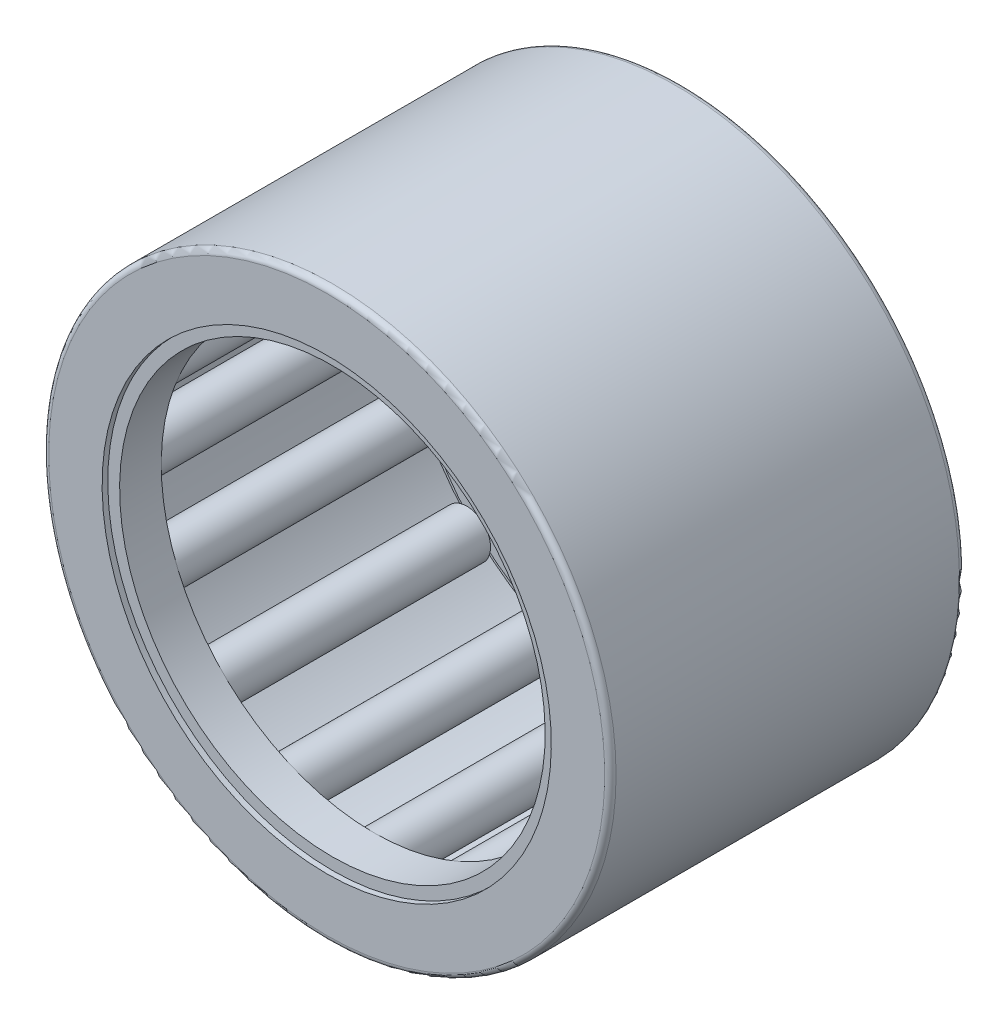
from build123d import *

# Parameters (mm, degrees)
SKETCH2_W         = 11.641666666
SKETCH2_H         = 0.79375
SKETCH3_W         = 13.758333334
SKETCH3_H         = 0.264583334
CIRPATTERN1_COUNT = 16
CIRPATTERN1_ANGLE = 337.5
FILLET1_R         = 0.254
SKETCH4_W         = 1.862666667
SKETCH4_H         = 0.529166667
SKETCH5_W         = 1.862666667
SKETCH5_H         = 0.529166667


with BuildPart() as part:
    # Sketch1 → Revolve1 (revolve)
    with BuildSketch(Plane(origin=(0, 0, 0), x_dir=(0, 0, -1), z_dir=(1, 0, 0))):
        Polygon((-7.9375, 12.7), (7.9375, 12.7), (7.9375, 10.054166667), (6.879166667, 10.054166667), (6.879166667, 11.641666667), (-6.879166667, 11.641666667), (-6.879166667, 10.054166667), (-7.9375, 10.054166667), align=None)
    revolve(axis=Axis((0, 0, 7.9375), (0, 0, -1)))

    # Fillet1
    fillet1_edges = [part.edges().sort_by_distance(p)[0] for p in [
        (0, -12.7, 7.9375),
        (0, -12.7, -7.9375),
    ]]
    fillet(fillet1_edges, radius=FILLET1_R)


with BuildPart() as body_2:
    # Sketch2 → Revolve2 (revolve)
    with BuildSketch(Plane(origin=(0, 0, 0), x_dir=(0, 0, -1), z_dir=(1, 0, 0))):
        with Locations((0, 11.244791667)):
            Rectangle(SKETCH2_W, SKETCH2_H)
    revolve(axis=Axis((0, 10.583333333, 5.820833333), (0, 0, -1)))


with BuildPart() as body_3:
    # Sketch3 → Revolve3 (revolve)
    with BuildSketch(Plane(origin=(0, 0, 0), x_dir=(0, 0, -1), z_dir=(1, 0, 0))):
        with Locations((0, 10.715625)):
            Rectangle(SKETCH3_W, SKETCH3_H)
    revolve(axis=Axis((0, 10.583333333, 6.879166667), (0, 0, -1)))


with BuildPart() as cirpattern1_1:
    # CirPattern1: pattern copy
    add(body_2.part.rotate(Axis((0, 0, -7.9375), (0, 0, 1)), 1 * CIRPATTERN1_ANGLE / (CIRPATTERN1_COUNT - 1)))


with BuildPart() as cirpattern1_2:
    # CirPattern1: pattern copy
    add(body_2.part.rotate(Axis((0, 0, -7.9375), (0, 0, 1)), 2 * CIRPATTERN1_ANGLE / (CIRPATTERN1_COUNT - 1)))


with BuildPart() as cirpattern1_3:
    # CirPattern1: pattern copy
    add(body_2.part.rotate(Axis((0, 0, -7.9375), (0, 0, 1)), 3 * CIRPATTERN1_ANGLE / (CIRPATTERN1_COUNT - 1)))


with BuildPart() as cirpattern1_4:
    # CirPattern1: pattern copy
    add(body_2.part.rotate(Axis((0, 0, -7.9375), (0, 0, 1)), 4 * CIRPATTERN1_ANGLE / (CIRPATTERN1_COUNT - 1)))


with BuildPart() as cirpattern1_5:
    # CirPattern1: pattern copy
    add(body_2.part.rotate(Axis((0, 0, -7.9375), (0, 0, 1)), 5 * CIRPATTERN1_ANGLE / (CIRPATTERN1_COUNT - 1)))


with BuildPart() as cirpattern1_6:
    # CirPattern1: pattern copy
    add(body_2.part.rotate(Axis((0, 0, -7.9375), (0, 0, 1)), 6 * CIRPATTERN1_ANGLE / (CIRPATTERN1_COUNT - 1)))


with BuildPart() as cirpattern1_7:
    # CirPattern1: pattern copy
    add(body_2.part.rotate(Axis((0, 0, -7.9375), (0, 0, 1)), 7 * CIRPATTERN1_ANGLE / (CIRPATTERN1_COUNT - 1)))


with BuildPart() as cirpattern1_8:
    # CirPattern1: pattern copy
    add(body_2.part.rotate(Axis((0, 0, -7.9375), (0, 0, 1)), 8 * CIRPATTERN1_ANGLE / (CIRPATTERN1_COUNT - 1)))


with BuildPart() as cirpattern1_9:
    # CirPattern1: pattern copy
    add(body_2.part.rotate(Axis((0, 0, -7.9375), (0, 0, 1)), 9 * CIRPATTERN1_ANGLE / (CIRPATTERN1_COUNT - 1)))


with BuildPart() as cirpattern1_10:
    # CirPattern1: pattern copy
    add(body_2.part.rotate(Axis((0, 0, -7.9375), (0, 0, 1)), 10 * CIRPATTERN1_ANGLE / (CIRPATTERN1_COUNT - 1)))


with BuildPart() as cirpattern1_11:
    # CirPattern1: pattern copy
    add(body_2.part.rotate(Axis((0, 0, -7.9375), (0, 0, 1)), 11 * CIRPATTERN1_ANGLE / (CIRPATTERN1_COUNT - 1)))


with BuildPart() as cirpattern1_12:
    # CirPattern1: pattern copy
    add(body_2.part.rotate(Axis((0, 0, -7.9375), (0, 0, 1)), 12 * CIRPATTERN1_ANGLE / (CIRPATTERN1_COUNT - 1)))


with BuildPart() as cirpattern1_13:
    # CirPattern1: pattern copy
    add(body_2.part.rotate(Axis((0, 0, -7.9375), (0, 0, 1)), 13 * CIRPATTERN1_ANGLE / (CIRPATTERN1_COUNT - 1)))


with BuildPart() as cirpattern1_14:
    # CirPattern1: pattern copy
    add(body_2.part.rotate(Axis((0, 0, -7.9375), (0, 0, 1)), 14 * CIRPATTERN1_ANGLE / (CIRPATTERN1_COUNT - 1)))


with BuildPart() as cirpattern1_15:
    # CirPattern1: pattern copy
    add(body_2.part.rotate(Axis((0, 0, -7.9375), (0, 0, 1)), 15 * CIRPATTERN1_ANGLE / (CIRPATTERN1_COUNT - 1)))


with BuildPart() as cirpattern1_16:
    # CirPattern1: pattern copy
    add(body_3.part.rotate(Axis((0, 0, -7.9375), (0, 0, 1)), 1 * CIRPATTERN1_ANGLE / (CIRPATTERN1_COUNT - 1)))


with BuildPart() as cirpattern1_17:
    # CirPattern1: pattern copy
    add(body_3.part.rotate(Axis((0, 0, -7.9375), (0, 0, 1)), 2 * CIRPATTERN1_ANGLE / (CIRPATTERN1_COUNT - 1)))


with BuildPart() as cirpattern1_18:
    # CirPattern1: pattern copy
    add(body_3.part.rotate(Axis((0, 0, -7.9375), (0, 0, 1)), 3 * CIRPATTERN1_ANGLE / (CIRPATTERN1_COUNT - 1)))


with BuildPart() as cirpattern1_19:
    # CirPattern1: pattern copy
    add(body_3.part.rotate(Axis((0, 0, -7.9375), (0, 0, 1)), 4 * CIRPATTERN1_ANGLE / (CIRPATTERN1_COUNT - 1)))


with BuildPart() as cirpattern1_20:
    # CirPattern1: pattern copy
    add(body_3.part.rotate(Axis((0, 0, -7.9375), (0, 0, 1)), 5 * CIRPATTERN1_ANGLE / (CIRPATTERN1_COUNT - 1)))


with BuildPart() as cirpattern1_21:
    # CirPattern1: pattern copy
    add(body_3.part.rotate(Axis((0, 0, -7.9375), (0, 0, 1)), 6 * CIRPATTERN1_ANGLE / (CIRPATTERN1_COUNT - 1)))


with BuildPart() as cirpattern1_22:
    # CirPattern1: pattern copy
    add(body_3.part.rotate(Axis((0, 0, -7.9375), (0, 0, 1)), 7 * CIRPATTERN1_ANGLE / (CIRPATTERN1_COUNT - 1)))


with BuildPart() as cirpattern1_23:
    # CirPattern1: pattern copy
    add(body_3.part.rotate(Axis((0, 0, -7.9375), (0, 0, 1)), 8 * CIRPATTERN1_ANGLE / (CIRPATTERN1_COUNT - 1)))


with BuildPart() as cirpattern1_24:
    # CirPattern1: pattern copy
    add(body_3.part.rotate(Axis((0, 0, -7.9375), (0, 0, 1)), 9 * CIRPATTERN1_ANGLE / (CIRPATTERN1_COUNT - 1)))


with BuildPart() as cirpattern1_25:
    # CirPattern1: pattern copy
    add(body_3.part.rotate(Axis((0, 0, -7.9375), (0, 0, 1)), 10 * CIRPATTERN1_ANGLE / (CIRPATTERN1_COUNT - 1)))


with BuildPart() as cirpattern1_26:
    # CirPattern1: pattern copy
    add(body_3.part.rotate(Axis((0, 0, -7.9375), (0, 0, 1)), 11 * CIRPATTERN1_ANGLE / (CIRPATTERN1_COUNT - 1)))


with BuildPart() as cirpattern1_27:
    # CirPattern1: pattern copy
    add(body_3.part.rotate(Axis((0, 0, -7.9375), (0, 0, 1)), 12 * CIRPATTERN1_ANGLE / (CIRPATTERN1_COUNT - 1)))


with BuildPart() as cirpattern1_28:
    # CirPattern1: pattern copy
    add(body_3.part.rotate(Axis((0, 0, -7.9375), (0, 0, 1)), 13 * CIRPATTERN1_ANGLE / (CIRPATTERN1_COUNT - 1)))


with BuildPart() as cirpattern1_29:
    # CirPattern1: pattern copy
    add(body_3.part.rotate(Axis((0, 0, -7.9375), (0, 0, 1)), 14 * CIRPATTERN1_ANGLE / (CIRPATTERN1_COUNT - 1)))


with BuildPart() as cirpattern1_30:
    # CirPattern1: pattern copy
    add(body_3.part.rotate(Axis((0, 0, -7.9375), (0, 0, 1)), 15 * CIRPATTERN1_ANGLE / (CIRPATTERN1_COUNT - 1)))


with BuildPart() as body_34:
    # Sketch4 → Revolve4 (revolve)
    with BuildSketch(Plane(origin=(0, 0, 0), x_dir=(0, 0, -1), z_dir=(1, 0, 0))):
        with Locations((6.752166667, 9.789583334)):
            Rectangle(SKETCH4_W, SKETCH4_H)
    revolve(axis=Axis((0, 0, 7.9375), (0, 0, -1)))


with BuildPart() as body_35:
    # Sketch5 → Revolve5 (revolve)
    with BuildSketch(Plane(origin=(0, 0, 0), x_dir=(0, 0, -1), z_dir=(1, 0, 0))):
        with Locations((-6.752166667, 9.789583334)):
            Rectangle(SKETCH5_W, SKETCH5_H)
    revolve(axis=Axis((0, 0, 7.9375), (0, 0, -1)))


solid = Compound([part.part, body_2.part, body_3.part, cirpattern1_1.part, cirpattern1_2.part, cirpattern1_3.part, cirpattern1_4.part, cirpattern1_5.part, cirpattern1_6.part, cirpattern1_7.part, cirpattern1_8.part, cirpattern1_9.part, cirpattern1_10.part, cirpattern1_11.part, cirpattern1_12.part, cirpattern1_13.part, cirpattern1_14.part, cirpattern1_15.part, cirpattern1_16.part, cirpattern1_17.part, cirpattern1_18.part, cirpattern1_19.part, cirpattern1_20.part, cirpattern1_21.part, cirpattern1_22.part, cirpattern1_23.part, cirpattern1_24.part, cirpattern1_25.part, cirpattern1_26.part, cirpattern1_27.part, cirpattern1_28.part, cirpattern1_29.part, cirpattern1_30.part, body_34.part, body_35.part])
